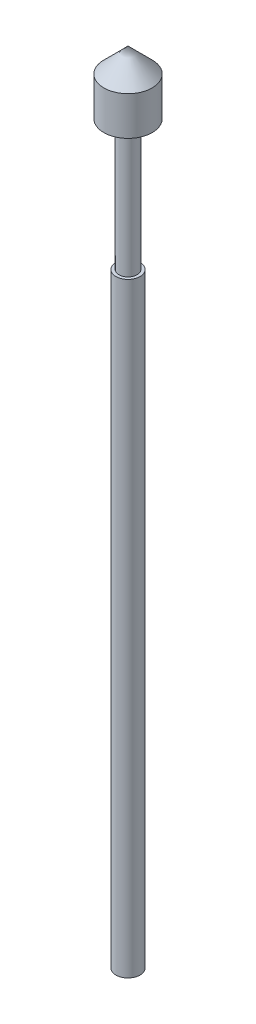
from build123d import *


with BuildPart() as part:
    # Sketch1 → Revolve1 (revolve)
    with BuildSketch(Plane.XY):
        Polygon((0, 0), (0, 33), (1, 32), (1, 30.4), (0.375, 30.4), (0.375, 25), (0.5, 25), (0.5, 0), align=None)
    revolve(axis=Axis((0, 0, 0), (0, 1, 0)))


solid = part.part
